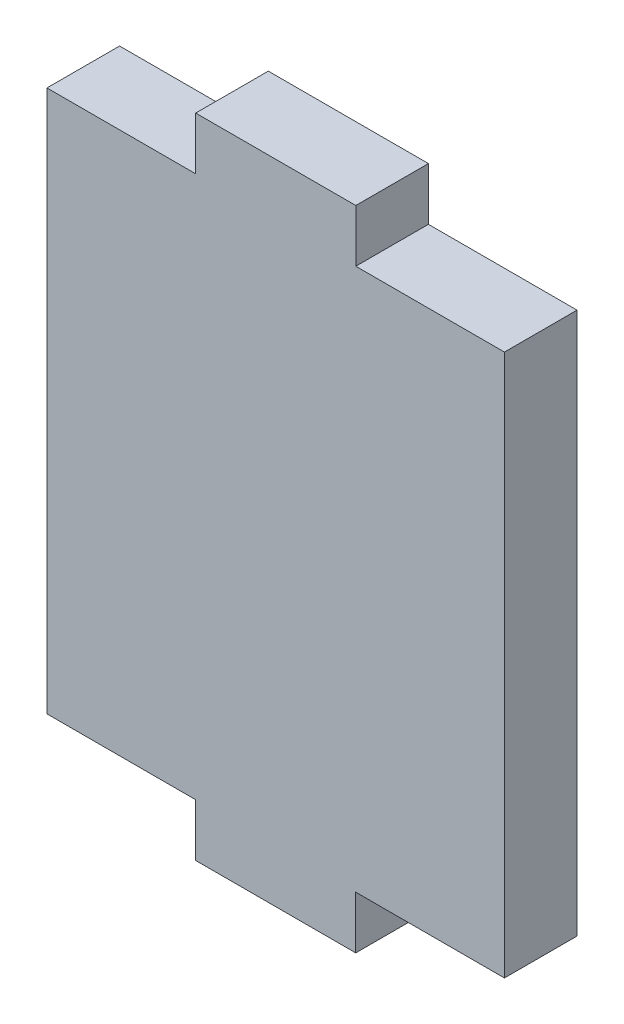
from build123d import *

# Parameters (mm, degrees)
SKETCH1_W           = 20
SKETCH1_H           = 23.7
BOSS_EXTRUDE1_DEPTH = 3.175
SKETCH2_W           = 7
SKETCH2_H           = 2.3
BOSS_EXTRUDE2_DEPTH = 3.175


with BuildPart() as part:
    # Sketch1 → Boss-Extrude1 (new body)
    with BuildSketch(Plane.XY):
        with Locations((10, 11.85)):
            Rectangle(SKETCH1_W, SKETCH1_H)
    extrude(amount=BOSS_EXTRUDE1_DEPTH)

    # Sketch2 → Boss-Extrude2 (add)
    with BuildSketch(Plane.XY.offset(3.175)):
        with Locations((10.002051165, 24.85)):
            Rectangle(SKETCH2_W, SKETCH2_H)
        with Locations((10, -1.15)):
            Rectangle(SKETCH2_W, SKETCH2_H)
    extrude(amount=-BOSS_EXTRUDE2_DEPTH)


solid = part.part
